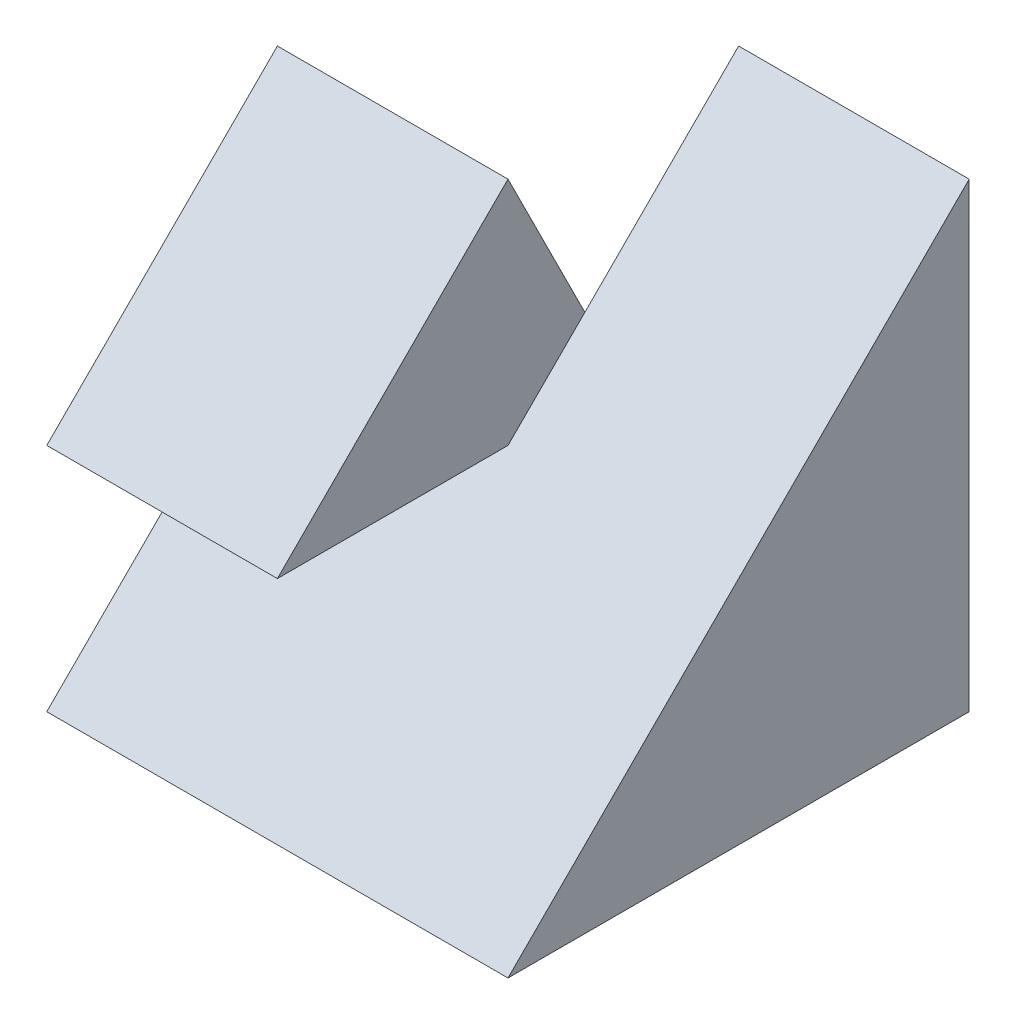
from build123d import *

# Parameters (mm, degrees)
SKETCH1_W           = 4
SKETCH1_H           = 4
BOSS_EXTRUDE1_DEPTH = 4
CUT_EXTRUDE1_DEPTH  = 2
CUT_EXTRUDE2_DEPTH  = 2


with BuildPart() as part:
    # Sketch1 → Boss-Extrude1 (new body)
    with BuildSketch(Plane(origin=(0, 0, 0), x_dir=(1, 0, 0), z_dir=(0, 1, 0))):
        Rectangle(SKETCH1_W, SKETCH1_H)
    extrude(amount=BOSS_EXTRUDE1_DEPTH)

    # Sketch2 → Cut-Extrude1 (cut)
    with BuildSketch(Plane.ZY.offset(2)):
        Polygon((0, 2), (2, 0), (2, 2), align=None)
        Polygon((0, 4), (2, 2), (2, 4), align=None)
        Polygon((-2, 0), (0, 4), (-2, 4), (-2, 2), align=None)
    extrude(amount=-CUT_EXTRUDE1_DEPTH, mode=Mode.SUBTRACT)

    # Sketch3 → Cut-Extrude2 (cut)
    with BuildSketch(Plane(origin=(2, 0, 0), x_dir=(0, 0, -1), z_dir=(1, 0, 0))):
        Polygon((-2, 0), (2, 4), (-2, 4.116557223), align=None)
    extrude(amount=-CUT_EXTRUDE2_DEPTH, mode=Mode.SUBTRACT)


solid = part.part
